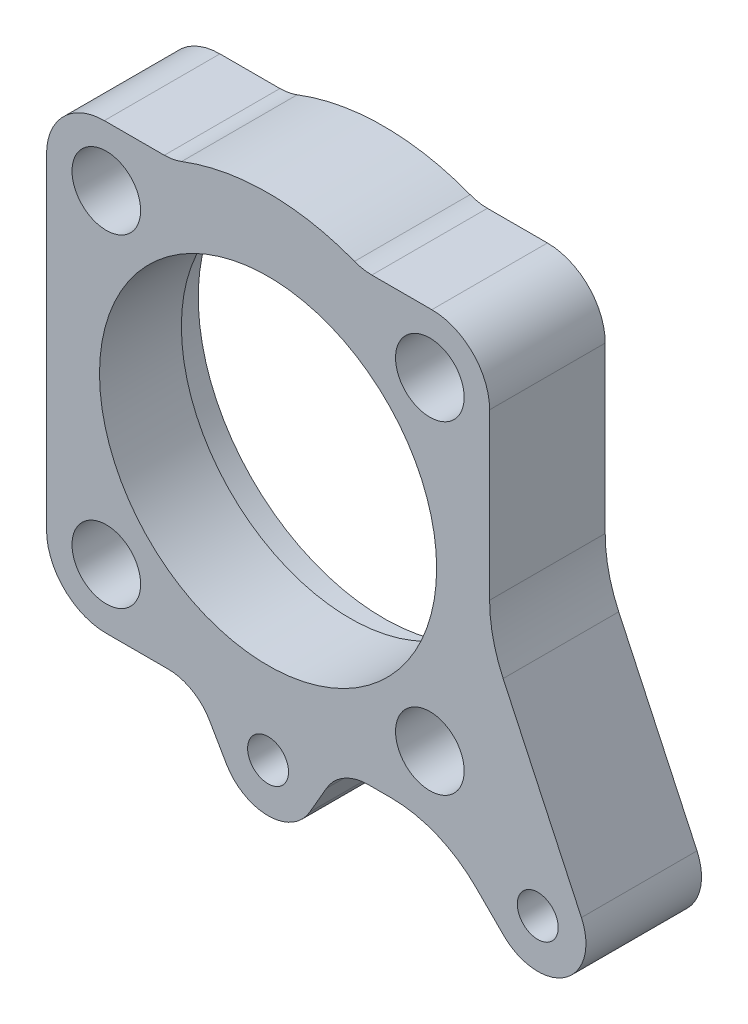
from build123d import *

# Parameters (mm, degrees)
SKETCH1_R              = 31
BASE_EXTRUDE_DEPTH     = 12
M10_GEVINDHULLER_D     = 8.5
M10_GEVINDHULLER_DEPTH = 24
M10_GEVINDHULLER_TIP   = 2.553657631
SKETCH7_R              = 7.125
F_14_25_HULLER_DEPTH   = 25


with BuildPart() as part:
    # Sketch1 → Base-Extrude (new body, symmetric)
    with BuildSketch(Plane.XY):
        with BuildLine():
            Line((34, 46), (21.540659229, 46))
            ThreePointArc((21.540659229, 46), (19.71491737, 46.168079197), (17.950549357, 46.666666667))
            ThreePointArc((17.950549357, 46.666666667), (0, 50), (-17.950549357, 46.666666667))
            ThreePointArc((-17.950549357, 46.666666667), (-19.71491737, 46.168079197), (-21.540659229, 46))
            Line((-21.540659229, 46), (-34, 46))
            ThreePointArc((-34, 46), (-42.485281374, 42.485281374), (-46, 34))
            Line((-46, 34), (-46, 0))
            Line((-46, 0), (-46, -33.587572106))
            ThreePointArc((-46, -33.587572106), (-42.364484041, -42.364484041), (-33.587572106, -46))
            Line((-33.587572106, -46), (-20.784609691, -46))
            ThreePointArc((-20.784609691, -46), (-15.784609691, -47.339745962), (-12.124355653, -51))
            Line((-12.124355653, -51), (-8.660254038, -57))
            ThreePointArc((-8.660254038, -57), (0, -62), (8.660254038, -57))
            Line((8.660254038, -57), (12.124355653, -51))
            ThreePointArc((12.124355653, -51), (15.784609691, -47.339745962), (20.784609691, -46))
            Line((20.784609691, -46), (25.502525317, -46))
            ThreePointArc((25.502525317, -46), (35.069611126, -47.903011687), (43.180194847, -53.32233047))
            Line((43.180194847, -53.32233047), (48.928932188, -59.071067812))
            ThreePointArc((48.928932188, -59.071067812), (61.735764364, -60.191520443), (65.06307787, -47.773817383))
            Line((65.06307787, -47.773817383), (48.810766389, -12.920622936))
            ThreePointArc((48.810766389, -12.920622936), (46.711119786, -6.735263502), (46, -0.242075084))
            Line((46, -0.242075084), (46, 34))
            ThreePointArc((46, 34), (42.485281374, 42.485281374), (34, 46))
        make_face()
        Circle(SKETCH1_R, mode=Mode.SUBTRACT)
    extrude(amount=BASE_EXTRUDE_DEPTH, both=True)

    # Sketch2 → Uddrejning (revolve, cut)
    with BuildSketch(Plane(origin=(0, 0, 0), x_dir=(0, 0, -1), z_dir=(1, 0, 0))):
        Polygon((12, 38.5), (5, 38.5), (5, 35), (-12, 35), (-12, 0), (12, 0), align=None)
    revolve(axis=Axis((0, 0, 0), (0, 0, -1)), mode=Mode.SUBTRACT)

    # M10 gevindhuller
    with Locations(Plane.XY.offset(12)):
        with Locations((56, -52), (0, -52)):
            Hole(M10_GEVINDHULLER_D / 2, depth=M10_GEVINDHULLER_DEPTH)
            with Locations((0, 0, -(M10_GEVINDHULLER_DEPTH + M10_GEVINDHULLER_TIP / 2))):  # 118° drill point
                Cone(0, M10_GEVINDHULLER_D / 2, M10_GEVINDHULLER_TIP, mode=Mode.SUBTRACT)

    # Sketch7 → ø14.25 huller (cut, through all)
    with BuildSketch(Plane.XY.offset(12)):
        with Locations((33.587572106, 33.587572106)):
            Circle(SKETCH7_R)
        with Locations((33.587572106, -33.587572106)):
            Circle(SKETCH7_R)
        with Locations((-33.587572106, -33.587572106)):
            Circle(SKETCH7_R)
        with Locations((-33.587572106, 33.587572106)):
            Circle(SKETCH7_R)
    extrude(amount=-F_14_25_HULLER_DEPTH, mode=Mode.SUBTRACT)


solid = part.part
